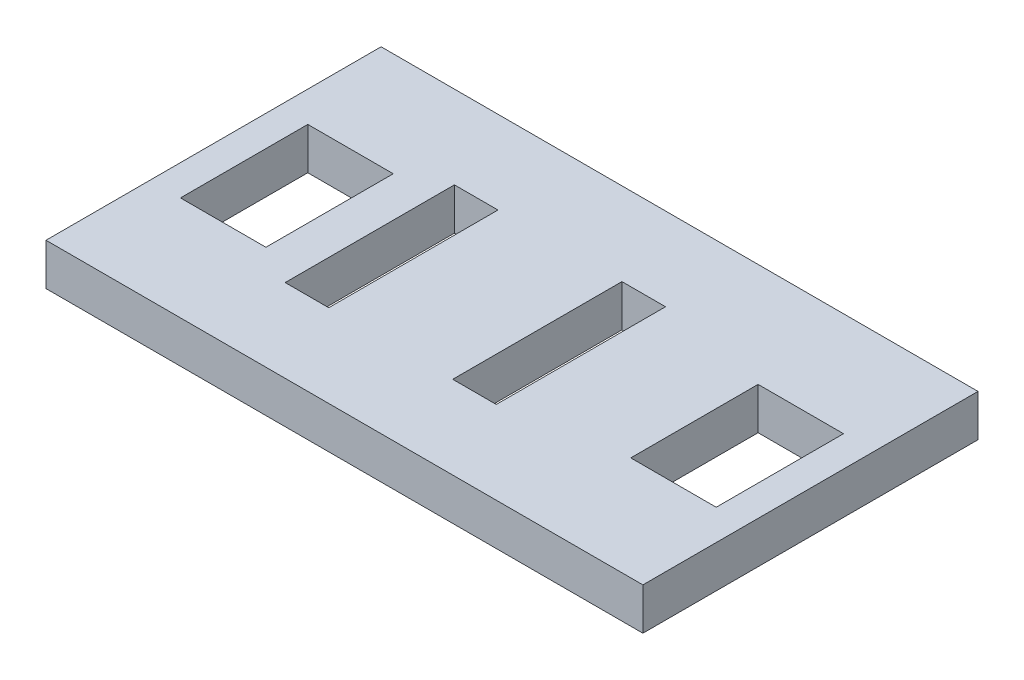
from build123d import *

# Parameters (mm, degrees)
SKETCH1_W           = 80.9625
SKETCH1_H           = 50.8
BOSS_EXTRUDE1_DEPTH = 6.35
SKETCH3_W           = 6.604
SKETCH3_H           = 25.654
CUT_EXTRUDE1_DEPTH  = 7.35
SKETCH4_W           = 4.7625
SKETCH4_H           = 50.8
BOSS_EXTRUDE2_DEPTH = 6.35
SKETCH5_W           = 12.954
SKETCH5_H           = 19.304
CUT_EXTRUDE2_DEPTH  = 7.35


with BuildPart() as part:
    # Sketch1 → Boss-Extrude1 (new body)
    with BuildSketch(Plane(origin=(0, 0, 0), x_dir=(1, 0, 0), z_dir=(0, 1, 0))):
        Rectangle(SKETCH1_W, SKETCH1_H)
    extrude(amount=BOSS_EXTRUDE1_DEPTH)

    # Sketch3 → Cut-Extrude1 (cut, through all)
    with BuildSketch(Plane(origin=(0, 0, 0), x_dir=(-1, 0, 0), z_dir=(0, -1, 0))):
        with Locations((18.25625, 0)):
            Rectangle(SKETCH3_W, SKETCH3_H)
        with Locations((-7.14375, 0)):
            Rectangle(SKETCH3_W, SKETCH3_H)
    extrude(amount=-CUT_EXTRUDE1_DEPTH, mode=Mode.SUBTRACT)

    # Sketch4 → Boss-Extrude2 (add)
    with BuildSketch(Plane(origin=(0, 6.35, 0), x_dir=(1, 0, 0), z_dir=(0, 1, 0))):
        with Locations((-42.8625, 0)):
            Rectangle(SKETCH4_W, SKETCH4_H)
        with Locations((42.8625, 0)):
            Rectangle(SKETCH4_W, SKETCH4_H)
    extrude(amount=-BOSS_EXTRUDE2_DEPTH)

    # Sketch5 → Cut-Extrude2 (cut, through all)
    with BuildSketch(Plane(origin=(0, 6.35, 0), x_dir=(1, 0, 0), z_dir=(0, 1, 0))):
        with Locations((34.13125, 0)):
            Rectangle(SKETCH5_W, SKETCH5_H)
        with Locations((-34.13125, 0)):
            Rectangle(SKETCH5_W, SKETCH5_H)
    extrude(amount=-CUT_EXTRUDE2_DEPTH, mode=Mode.SUBTRACT)


solid = part.part
